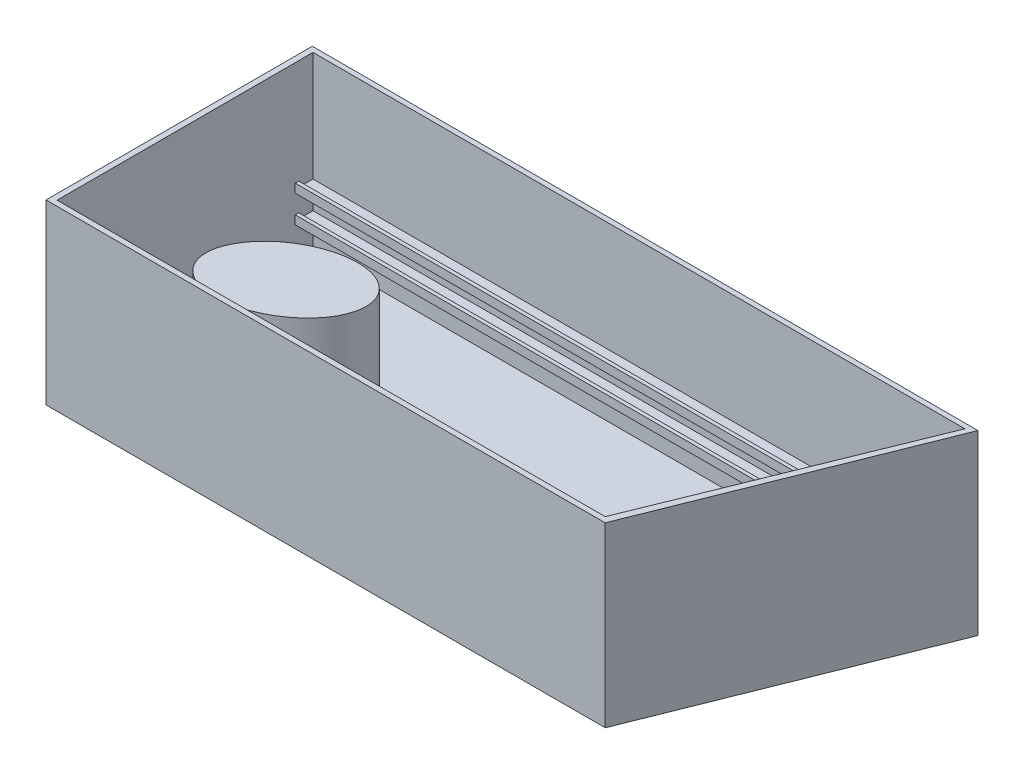
from build123d import *

# Parameters (mm, degrees)
BOSS_EXTRUDE1_DEPTH = 2540
CUT_EXTRUDE1_DEPTH  = 2463.8
SKETCH4_W           = 7188.60189706
SKETCH4_H           = 123.896573516
BOSS_EXTRUDE2_DEPTH = 254
SKETCH5_W           = 7188.581
SKETCH5_H           = 124.46
BOSS_EXTRUDE3_DEPTH = 254
SKETCH6_W           = 7188.581
SKETCH6_H           = 203.2
CUT_EXTRUDE2_DEPTH  = 76.2
SKETCH11_W          = 7188.60189706
SKETCH11_H          = 203.2
CUT_EXTRUDE3_DEPTH  = 76.2
SKETCH18_RX         = 966.922200264
SKETCH18_RY         = 638.624638674
BOSS_EXTRUDE4_DEPTH = 2032


with BuildPart() as part:
    # Sketch2 → Boss-Extrude1 (new body)
    with BuildSketch(Plane(origin=(0, 0, 0), x_dir=(1, 0, 0), z_dir=(0, 1, 0))):
        Polygon((0, 0), (-8001, 0), (-8001, 3810), (1524, 3810), align=None)
    extrude(amount=BOSS_EXTRUDE1_DEPTH)

    # Sketch3 → Cut-Extrude1 (cut)
    with BuildSketch(Plane(origin=(0, 2540, 0), x_dir=(1, 0, 0), z_dir=(0, 1, 0))):
        Polygon((-76.2, 76.2), (1408.686941169, 3738.242810126), (-7919.119940746, 3738.242810126), (-7919.119940746, 76.2), align=None)
    extrude(amount=-CUT_EXTRUDE1_DEPTH, mode=Mode.SUBTRACT)

    # Sketch4 → Boss-Extrude2 (add)
    with BuildSketch(Plane.XY.offset(-3738.242810126)):
        with Locations((-4324.818992216, 592.590354758)):
            Rectangle(SKETCH4_W, SKETCH4_H)
    extrude(amount=BOSS_EXTRUDE2_DEPTH)

    # Sketch5 → Boss-Extrude3 (add)
    with BuildSketch(Plane.XY.offset(-3738.242810126)):
        with Locations((-4324.829440746, 984.950312929)):
            Rectangle(SKETCH5_W, SKETCH5_H)
    extrude(amount=BOSS_EXTRUDE3_DEPTH)

    # Sketch6 → Cut-Extrude2 (cut)
    with BuildSketch(Plane(origin=(0, 1047.180312929, 0), x_dir=(1, 0, 0), z_dir=(0, 1, 0))):
        with Locations((-4324.829440746, 3636.642810126)):
            Rectangle(SKETCH6_W, SKETCH6_H)
    extrude(amount=-CUT_EXTRUDE2_DEPTH, mode=Mode.SUBTRACT)

    # Sketch11 → Cut-Extrude3 (cut)
    with BuildSketch(Plane(origin=(0, 654.538641516, 0), x_dir=(1, 0, 0), z_dir=(0, 1, 0))):
        with Locations((-4324.818992216, 3636.642810126)):
            Rectangle(SKETCH11_W, SKETCH11_H)
    extrude(amount=-CUT_EXTRUDE3_DEPTH, mode=Mode.SUBTRACT)

    # Sketch18 → Boss-Extrude4 (add)
    with BuildSketch(Plane(origin=(0, 76.2, 0), x_dir=(1, 0, 0), z_dir=(0, 1, 0))):
        with Locations(Location((-5727.951271989, 1161.666204476), (0, 0, 27.906193222))):
            Ellipse(SKETCH18_RX, SKETCH18_RY)
    extrude(amount=BOSS_EXTRUDE4_DEPTH)


solid = part.part
